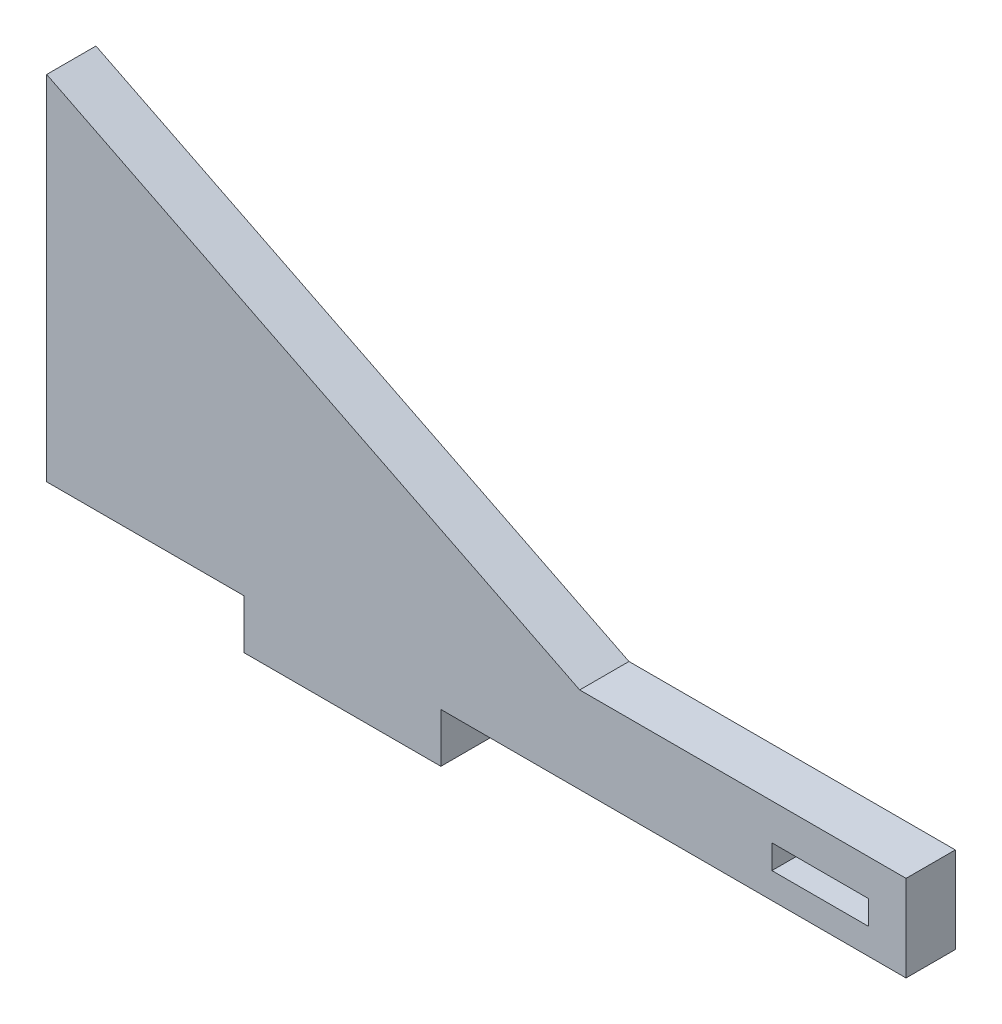
from build123d import *

# Parameters (mm, degrees)
BOSS_EXTRUDE1_DEPTH = 6.35
BOSS_EXTRUDE2_DEPTH = 6.35
SKETCH4_W           = 12.419699812
SKETCH4_H           = 3.102298877
CUT_EXTRUDE1_DEPTH  = 7.35


with BuildPart() as part:
    # Sketch1 → Boss-Extrude1 (new body)
    with BuildSketch(Plane.XY):
        Polygon((-38.1, -20.066), (-12.7, -20.066), (-12.7, -26.416), (12.7, -26.416), (12.7, -20.066), (38.1, -20.066), (38.1, -12.7), (-38.1, 25.4), align=None)
    extrude(amount=BOSS_EXTRUDE1_DEPTH)

    # Sketch2 → Boss-Extrude2 (add, through all)
    with BuildSketch(Plane.XY.offset(6.35)):
        Polygon((38.1, -20.066), (72.644, -20.066), (72.644, -12.7), (72.644, -8.944268717), (30.588537433, -8.944268717), (38.1, -12.7), align=None)
    extrude(amount=-BOSS_EXTRUDE2_DEPTH)

    # Sketch4 → Cut-Extrude1 (cut, through all)
    with BuildSketch(Plane(origin=(0, 0, 0), x_dir=(-1, 0, 0), z_dir=(0, 0, -1))):
        with Locations((-61.565974267, -15.172394908)):
            Rectangle(SKETCH4_W, SKETCH4_H)
    extrude(amount=-CUT_EXTRUDE1_DEPTH, mode=Mode.SUBTRACT)


solid = part.part
